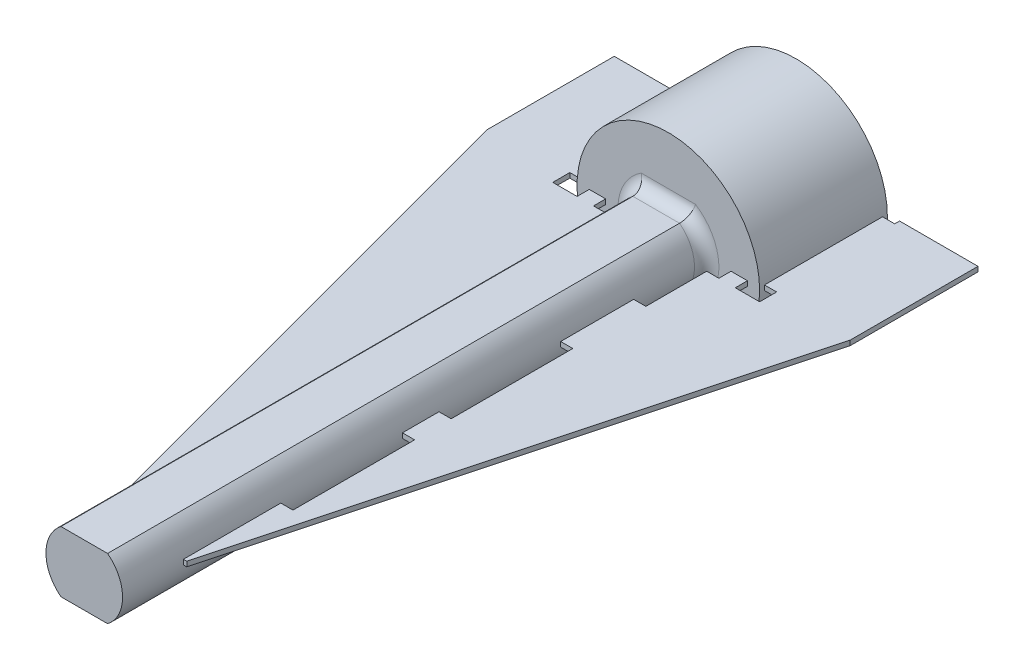
from build123d import *

# Parameters (mm, degrees)
SKETCH2_R                = 7.5
BOSS_EXTRUDE1_DEPTH      = 4
BOSS_EXTRUDE1_DEPTH_BACK = 5.5
SKETCH4_R                = 7.5
BOSS_EXTRUDE2_DEPTH      = 1
BOSS_EXTRUDE3_DEPTH      = 48
FILLET1_R                = 1
BOSS_EXTRUDE6_DEPTH      = 0.2
BOSS_EXTRUDE6_2_DEPTH    = 0.2


with BuildPart() as part:
    # Sketch2 → Boss-Extrude1 (new body, two sides)
    with BuildSketch(Plane.XY) as boss_extrude1_sk:
        with Locations((-178.577921964, 19.246491703)):
            Circle(SKETCH2_R)
        with BuildLine():
            ThreePointArc((-180.964561166, 16.918133172), (-181.154624072, 16.787356328), (-181.28128896, 16.594528692))
            ThreePointArc((-181.28128896, 16.594528692), (-181.41997807, 16.120570829), (-181.458725437, 15.628260596))
            ThreePointArc((-181.458725437, 15.628260596), (-181.203949235, 15.439313513), (-180.936821377, 15.26827369))
            ThreePointArc((-180.936821377, 15.26827369), (-180.490384316, 15.479377161), (-180.096604948, 15.777384768))
            ThreePointArc((-180.096604948, 15.777384768), (-179.961348857, 15.964286563), (-179.906617406, 16.188409207))
            ThreePointArc((-179.906617406, 16.188409207), (-179.860820758, 16.267909453), (-179.769487026, 16.276614146))
            ThreePointArc((-179.769487026, 16.276614146), (-179.651168987, 16.231837357), (-179.531173567, 16.191772177))
            ThreePointArc((-179.531173567, 16.191772177), (-179.465888148, 16.127309504), (-179.480632878, 16.036754465))
            ThreePointArc((-179.480632878, 16.036754465), (-179.57984376, 15.828466942), (-179.593124953, 15.598140867))
            ThreePointArc((-179.593124953, 15.598140867), (-179.476254314, 15.118336763), (-179.263655401, 14.67260991))
            ThreePointArc((-179.263655401, 14.67260991), (-178.948539196, 14.636365038), (-178.631679774, 14.621804135))
            ThreePointArc((-178.631679774, 14.621804135), (-178.350605674, 15.027843634), (-178.158586541, 15.482815477))
            ThreePointArc((-178.158586541, 15.482815477), (-178.134902228, 15.712305225), (-178.199564723, 15.933766853))
            ThreePointArc((-178.199564723, 15.933766853), (-178.199653785, 16.02551441), (-178.1249088, 16.078719761))
            ThreePointArc((-178.1249088, 16.078719761), (-178.000053977, 16.099100944), (-177.876102305, 16.124401191))
            ThreePointArc((-177.876102305, 16.124401191), (-177.787332137, 16.101217588), (-177.754823928, 16.015422258))
            ThreePointArc((-177.754823928, 16.015422258), (-177.736599312, 15.785434531), (-177.632938125, 15.579325702))
            ThreePointArc((-177.632938125, 15.579325702), (-177.29182313, 15.222238479), (-176.884843645, 14.942527158))
            ThreePointArc((-176.884843645, 14.942527158), (-176.59382257, 15.06869628), (-176.312133809, 15.21451588))
            ThreePointArc((-176.312133809, 15.21451588), (-176.271736248, 15.706693451), (-176.332928722, 16.196720191))
            ThreePointArc((-176.332928722, 16.196720191), (-176.427162379, 16.407306299), (-176.593892556, 16.566766447))
            ThreePointArc((-176.593892556, 16.566766447), (-176.639843465, 16.646177632), (-176.601715085, 16.72962731))
            ThreePointArc((-176.601715085, 16.72962731), (-176.503778228, 16.809705343), (-176.409083055, 16.893591835))
            ThreePointArc((-176.409083055, 16.893591835), (-176.320614032, 16.917899331), (-176.249563433, 16.8598525))
            ThreePointArc((-176.249563433, 16.8598525), (-176.118786588, 16.669789594), (-175.925958953, 16.543124706))
            ThreePointArc((-175.925958953, 16.543124706), (-175.45200109, 16.404435596), (-174.959690856, 16.365688229))
            ThreePointArc((-174.959690856, 16.365688229), (-174.770743774, 16.620464432), (-174.599703951, 16.88759229))
            ThreePointArc((-174.599703951, 16.88759229), (-174.810807422, 17.33402935), (-175.108815029, 17.727808718))
            ThreePointArc((-175.108815029, 17.727808718), (-175.295716824, 17.86306481), (-175.519839467, 17.91779626))
            ThreePointArc((-175.519839467, 17.91779626), (-175.599339714, 17.963592909), (-175.608044407, 18.05492664))
            ThreePointArc((-175.608044407, 18.05492664), (-175.563267617, 18.17324468), (-175.523202438, 18.2932401))
            ThreePointArc((-175.523202438, 18.2932401), (-175.458739765, 18.358525519), (-175.368184725, 18.343780789))
            ThreePointArc((-175.368184725, 18.343780789), (-175.159897203, 18.244569907), (-174.929571128, 18.231288713))
            ThreePointArc((-174.929571128, 18.231288713), (-174.449767024, 18.348159352), (-174.004040171, 18.560758265))
            ThreePointArc((-174.004040171, 18.560758265), (-173.967795299, 18.87587447), (-173.953234396, 19.192733892))
            ThreePointArc((-173.953234396, 19.192733892), (-174.359273895, 19.473807993), (-174.814245738, 19.665827125))
            ThreePointArc((-174.814245738, 19.665827125), (-175.043735485, 19.689511439), (-175.265197114, 19.624848944))
            ThreePointArc((-175.265197114, 19.624848944), (-175.356944671, 19.624759881), (-175.410150022, 19.699504867))
            ThreePointArc((-175.410150022, 19.699504867), (-175.430531205, 19.824359689), (-175.455831451, 19.948311361))
            ThreePointArc((-175.455831451, 19.948311361), (-175.432647848, 20.037081529), (-175.346852519, 20.069589738))
            ThreePointArc((-175.346852519, 20.069589738), (-175.116864792, 20.087814355), (-174.910755963, 20.191475542))
            ThreePointArc((-174.910755963, 20.191475542), (-174.553668739, 20.532590536), (-174.273957418, 20.939570022))
            ThreePointArc((-174.273957418, 20.939570022), (-174.400126541, 21.230591097), (-174.54594614, 21.512279857))
            ThreePointArc((-174.54594614, 21.512279857), (-175.038123712, 21.552677419), (-175.528150452, 21.491484944))
            ThreePointArc((-175.528150452, 21.491484944), (-175.73873656, 21.397251288), (-175.898196708, 21.23052111))
            ThreePointArc((-175.898196708, 21.23052111), (-175.977607892, 21.184570201), (-176.061057571, 21.222698582))
            ThreePointArc((-176.061057571, 21.222698582), (-176.141135604, 21.320635439), (-176.225022096, 21.415330612))
            ThreePointArc((-176.225022096, 21.415330612), (-176.249329591, 21.503799634), (-176.191282761, 21.574850234))
            ThreePointArc((-176.191282761, 21.574850234), (-176.001219855, 21.705627078), (-175.874554967, 21.898454714))
            ThreePointArc((-175.874554967, 21.898454714), (-175.735865857, 22.372412576), (-175.69711849, 22.86472281))
            ThreePointArc((-175.69711849, 22.86472281), (-175.951894692, 23.053669893), (-176.21902255, 23.224709716))
            ThreePointArc((-176.21902255, 23.224709716), (-176.665459611, 23.013606245), (-177.059238979, 22.715598637))
            ThreePointArc((-177.059238979, 22.715598637), (-177.19449507, 22.528696843), (-177.249226521, 22.304574199))
            ThreePointArc((-177.249226521, 22.304574199), (-177.295023169, 22.225073952), (-177.386356901, 22.21636926))
            ThreePointArc((-177.386356901, 22.21636926), (-177.50467494, 22.261146049), (-177.62467036, 22.301211229))
            ThreePointArc((-177.62467036, 22.301211229), (-177.68995578, 22.365673902), (-177.67521105, 22.456228941))
            ThreePointArc((-177.67521105, 22.456228941), (-177.576000167, 22.664516463), (-177.562718974, 22.894842539))
            ThreePointArc((-177.562718974, 22.894842539), (-177.679589613, 23.374646643), (-177.892188526, 23.820373495))
            ThreePointArc((-177.892188526, 23.820373495), (-178.207304731, 23.856618368), (-178.524164153, 23.871179271))
            ThreePointArc((-178.524164153, 23.871179271), (-178.805238253, 23.465139771), (-178.997257386, 23.010167929))
            ThreePointArc((-178.997257386, 23.010167929), (-179.0209417, 22.780678181), (-178.956279204, 22.559216553))
            ThreePointArc((-178.956279204, 22.559216553), (-178.956190142, 22.467468995), (-179.030935127, 22.414263644))
            ThreePointArc((-179.030935127, 22.414263644), (-179.15578995, 22.393882462), (-179.279741622, 22.368582215))
            ThreePointArc((-179.279741622, 22.368582215), (-179.36851179, 22.391765818), (-179.401019999, 22.477561148))
            ThreePointArc((-179.401019999, 22.477561148), (-179.419244616, 22.707548874), (-179.522905803, 22.913657703))
            ThreePointArc((-179.522905803, 22.913657703), (-179.864020797, 23.270744927), (-180.271000283, 23.550456248))
            ThreePointArc((-180.271000283, 23.550456248), (-180.562021357, 23.424287126), (-180.843710118, 23.278467526))
            ThreePointArc((-180.843710118, 23.278467526), (-180.88410768, 22.786289955), (-180.822915205, 22.296263215))
            ThreePointArc((-180.822915205, 22.296263215), (-180.728681548, 22.085677107), (-180.561951371, 21.926216958))
            ThreePointArc((-180.561951371, 21.926216958), (-180.516000462, 21.846805774), (-180.554128842, 21.763356096))
            ThreePointArc((-180.554128842, 21.763356096), (-180.6520657, 21.683278063), (-180.746760873, 21.59939157))
            ThreePointArc((-180.746760873, 21.59939157), (-180.835229895, 21.575084075), (-180.906280494, 21.633130906))
            ThreePointArc((-180.906280494, 21.633130906), (-181.037057339, 21.823193811), (-181.229884975, 21.9498587))
            ThreePointArc((-181.229884975, 21.9498587), (-181.703842837, 22.08854781), (-182.196153071, 22.127295177))
            ThreePointArc((-182.196153071, 22.127295177), (-182.385100154, 21.872518974), (-182.556139976, 21.605391116))
            ThreePointArc((-182.556139976, 21.605391116), (-182.345036505, 21.158954055), (-182.047028898, 20.765174687))
            ThreePointArc((-182.047028898, 20.765174687), (-181.860127103, 20.629918596), (-181.63600446, 20.575187146))
            ThreePointArc((-181.63600446, 20.575187146), (-181.556504213, 20.529390497), (-181.54779952, 20.438056766))
            ThreePointArc((-181.54779952, 20.438056766), (-181.59257631, 20.319738726), (-181.632641489, 20.199743306))
            ThreePointArc((-181.632641489, 20.199743306), (-181.697104162, 20.134457887), (-181.787659202, 20.149202617))
            ThreePointArc((-181.787659202, 20.149202617), (-181.995946724, 20.248413499), (-182.226272799, 20.261694692))
            ThreePointArc((-182.226272799, 20.261694692), (-182.706076904, 20.144824054), (-183.151803756, 19.932225141))
            ThreePointArc((-183.151803756, 19.932225141), (-183.188048629, 19.617108936), (-183.202609531, 19.300249514))
            ThreePointArc((-183.202609531, 19.300249514), (-182.796570032, 19.019175413), (-182.34159819, 18.82715628))
            ThreePointArc((-182.34159819, 18.82715628), (-182.112108442, 18.803471967), (-181.890646814, 18.868134462))
            ThreePointArc((-181.890646814, 18.868134462), (-181.798899256, 18.868223525), (-181.745693905, 18.793478539))
            ThreePointArc((-181.745693905, 18.793478539), (-181.725312723, 18.668623716), (-181.700012476, 18.544672045))
            ThreePointArc((-181.700012476, 18.544672045), (-181.723196079, 18.455901876), (-181.808991408, 18.423393667))
            ThreePointArc((-181.808991408, 18.423393667), (-182.038979135, 18.405169051), (-182.245087964, 18.301507864))
            ThreePointArc((-182.245087964, 18.301507864), (-182.602175188, 17.96039287), (-182.881886509, 17.553413384))
            ThreePointArc((-182.881886509, 17.553413384), (-182.755717387, 17.262392309), (-182.609897787, 16.980703549))
            ThreePointArc((-182.609897787, 16.980703549), (-182.117720216, 16.940305987), (-181.627693476, 17.001498461))
            ThreePointArc((-181.627693476, 17.001498461), (-181.417107367, 17.095732118), (-181.257647219, 17.262462296))
            ThreePointArc((-181.257647219, 17.262462296), (-181.178236035, 17.308413205), (-181.094786356, 17.270284824))
            ThreePointArc((-181.094786356, 17.270284824), (-181.014708323, 17.172347967), (-180.930821831, 17.077652794))
            ThreePointArc((-180.930821831, 17.077652794), (-180.906514336, 16.989183772), (-180.964561166, 16.918133172))
        make_face(mode=Mode.SUBTRACT)
    extrude(amount=BOSS_EXTRUDE1_DEPTH)
    extrude(boss_extrude1_sk.sketch, amount=-BOSS_EXTRUDE1_DEPTH_BACK)

    # Sketch4 → Boss-Extrude2 (add)
    with BuildSketch(Plane.XY.offset(4)):
        with Locations((-178.577921964, 19.246491703)):
            Circle(SKETCH4_R)
    extrude(amount=BOSS_EXTRUDE2_DEPTH)

    # Sketch6 → Boss-Extrude3 (add)
    with BuildSketch(Plane.XY.offset(5)):
        with BuildLine():
            Line((-180.494298753, 21.746491703), (-176.661545174, 21.746491703))
            ThreePointArc((-176.661545174, 21.746491703), (-175.427921964, 19.246491703), (-176.661545174, 16.746491703))
            Line((-176.661545174, 16.746491703), (-180.494298753, 16.746491703))
            ThreePointArc((-180.494298753, 16.746491703), (-181.727921964, 19.246491703), (-180.494298753, 21.746491703))
        make_face()
    extrude(amount=BOSS_EXTRUDE3_DEPTH)

    # Fillet1
    fillet1_edges = [part.edges().sort_by_distance(p)[0] for p in [
        (-175.427921964, 19.246491703, 5),
        (-178.577921964, 21.746491703, 5),
        (-181.727921964, 19.246491703, 5),
        (-178.577921964, 16.746491703, 5),
    ]]
    fillet(fillet1_edges, radius=FILLET1_R)


with BuildPart() as body_2:
    # Sketch7 → Boss-Extrude6 (new body, symmetric)
    with BuildSketch(Plane(origin=(0, 19.246491703, 0), x_dir=(1, 0, 0), z_dir=(0, 1, 0))):
        Polygon((-182.727921964, -6), (-182.727921964, -11), (-181.727921964, -11), (-181.727921964, -17), (-182.727921964, -17), (-182.727921964, -27), (-181.727921964, -27), (-181.727921964, -30), (-182.727921964, -30), (-182.727921964, -40), (-181.727921964, -40), (-181.727921964, -48), (-182.002348878, -48), (-193.524164153, -5), (-193.524164153, 5.5), (-187.077921964, 5.5), (-187.077921964, 5.1), (-186.077921964, 5.1), (-186.077921964, -4.6), (-187.077921964, -4.6), (-187.077921964, -6), (-185.077921964, -6), (-185.077921964, -5), (-183.727921964, -5), (-183.727921964, -6), align=None)
    extrude(amount=BOSS_EXTRUDE6_DEPTH, both=True)


with BuildPart() as body_3:
    # Sketch7 → Boss-Extrude6 2 (new body, symmetric)
    with BuildSketch(Plane(origin=(0, 19.246491703, 0), x_dir=(1, 0, 0), z_dir=(0, 1, 0))):
        Polygon((-175.153495049, -48), (-175.427921964, -48), (-175.427921964, -40), (-174.427921964, -40), (-174.427921964, -30), (-175.427921964, -30), (-175.427921964, -27), (-174.427921964, -27), (-174.427921964, -17), (-175.427921964, -17), (-175.427921964, -11), (-174.427921964, -11), (-174.427921964, -6), (-173.427921964, -6), (-173.427921964, -5), (-172.077921964, -5), (-172.077921964, -6), (-170.077921964, -6), (-170.077921964, -4.6), (-171.077921964, -4.6), (-171.077921964, 5.1), (-170.077921964, 5.1), (-170.077921964, 5.5), (-163.631679774, 5.5), (-163.631679774, -5), align=None)
    extrude(amount=BOSS_EXTRUDE6_2_DEPTH, both=True)


solid = Compound([part.part, body_2.part, body_3.part])
